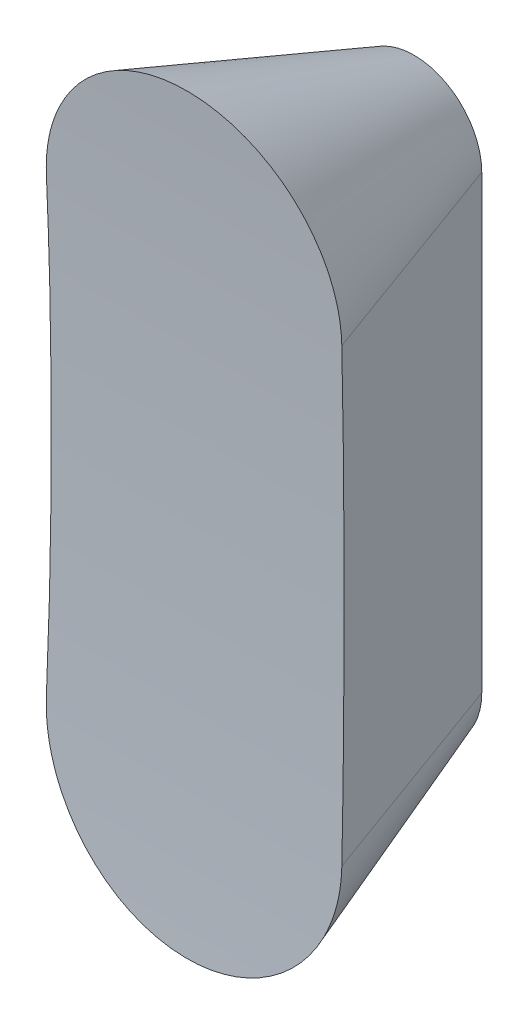
from build123d import *

# Parameters (mm, degrees)
RESSALTO_EXTRUS_O1_DEPTH   = 300
RESSALTO_EXTRUS_O1_TAPER   = -20
CORTE_EXTRUS_O1_DEPTH      = 185.19107038
CORTE_EXTRUS_O1_DEPTH_BACK = 185.19107038


with BuildPart() as part:
    # Esboço1 → Ressalto-extrusão1 (new body)
    with BuildSketch(Plane.XY):
        with BuildLine():
            Line((75, -250), (75, 250))
            ThreePointArc((75, 250), (0, 325), (-75, 250))
            Line((-75, 250), (-75, -250))
            ThreePointArc((-75, -250), (0, -325), (75, -250))
        make_face()
    extrude(amount=RESSALTO_EXTRUS_O1_DEPTH, taper=RESSALTO_EXTRUS_O1_TAPER)

    # Esboço4 → Corte-extrusão1 (cut, two sides)
    with BuildSketch(Plane(origin=(0, 0, 0), x_dir=(0, 0, -1), z_dir=(1, 0, 0))) as corte_extrus_o1_sk:
        with BuildLine():
            Line((-329.933259094, 603.571428571), (-300, 803.571428571))
            Line((-300, 803.571428571), (-270.066740906, 603.571428571))
            add(Edge.make_bspline(
                [(-329.933259094, 603.571428571), (-391.958337138, 189.14894388), (-345.979168569, -447.42728801), (-300, -1084.0035199), (-254.020831431, -447.42728801), (-208.041662862, 189.14894388), (-270.066740906, 603.571428571)],
                knots=[3.663907475, 3.663907475, 3.663907475, 5.410092697, 5.410092697, 7.156277918, 7.156277918, 8.902463139, 8.902463139, 8.902463139], degree=2, weights=[1, 0.642459696, 1, 0.642459696, 1, 0.642459696, 1]))
        make_face()
    extrude(amount=CORTE_EXTRUS_O1_DEPTH, mode=Mode.SUBTRACT)
    extrude(corte_extrus_o1_sk.sketch, amount=-CORTE_EXTRUS_O1_DEPTH_BACK, mode=Mode.SUBTRACT)


solid = part.part
